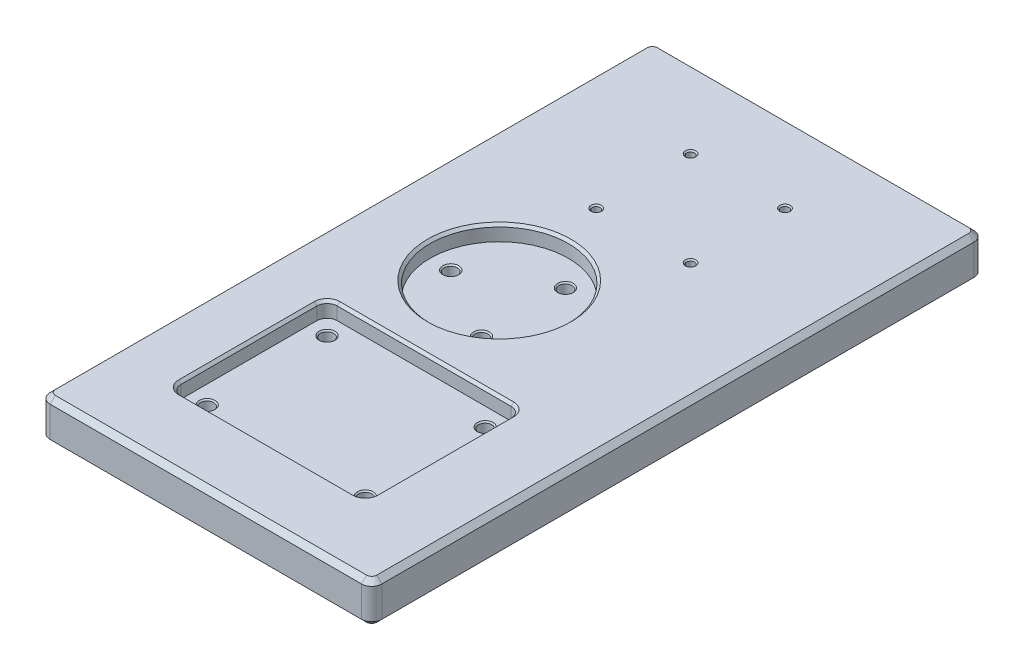
from build123d import *

# Parameters (mm, degrees)
SKETCH1_W           = 130
SKETCH1_H           = 240
BOSS_EXTRUDE1_DEPTH = 16
SKETCH7_W           = 76.2
SKETCH7_H           = 61.2
CUT_EXTRUDE5_DEPTH  = 6
SKETCH2_R           = 2.6
CUT_EXTRUDE1_DEPTH  = 11
SKETCH8_R           = 27.1
CUT_EXTRUDE6_DEPTH  = 6
SKETCH9_R           = 2.6
CUT_EXTRUDE7_DEPTH  = 11
SKETCH5_R           = 1.55
CUT_EXTRUDE3_DEPTH  = 17
SKETCH4_R           = 10
CUT_EXTRUDE2_DEPTH  = 5
SKETCH11_R          = 10
CUT_EXTRUDE8_DEPTH  = 6
FILLET1_R           = 4
CHAMFER3_SIZE       = 2
CHAMFER1_SIZE       = 1
CHAMFER2_SIZE       = 0.5


with BuildPart() as part:
    # Sketch1 → Boss-Extrude1 (new body)
    with BuildSketch(Plane(origin=(0, 0, 0), x_dir=(1, 0, 0), z_dir=(0, 1, 0))):
        Rectangle(SKETCH1_W, SKETCH1_H)
    extrude(amount=BOSS_EXTRUDE1_DEPTH)

    # Sketch7 → Cut-Extrude5 (cut)
    with BuildSketch(Plane(origin=(0, 16, 0), x_dir=(1, 0, 0), z_dir=(0, 1, 0))):
        with Locations((-3, -62)):
            Rectangle(SKETCH7_W, SKETCH7_H)
    extrude(amount=-CUT_EXTRUDE5_DEPTH, mode=Mode.SUBTRACT)

    # Sketch2 → Cut-Extrude1 (cut, through all)
    with BuildSketch(Plane(origin=(0, 10, 0), x_dir=(1, 0, 0), z_dir=(0, 1, 0))):
        with Locations((-34, -85.5)):
            Circle(SKETCH2_R)
        with Locations((-34, -38.5)):
            Circle(SKETCH2_R)
        with Locations((28, -38.5)):
            Circle(SKETCH2_R)
        with Locations((28, -85.5)):
            Circle(SKETCH2_R)
    extrude(amount=-CUT_EXTRUDE1_DEPTH, mode=Mode.SUBTRACT)

    # Sketch8 → Cut-Extrude6 (cut)
    with BuildSketch(Plane(origin=(0, 16, 0), x_dir=(1, 0, 0), z_dir=(0, 1, 0))):
        with Locations((-13, 8)):
            Circle(SKETCH8_R)
    extrude(amount=-CUT_EXTRUDE6_DEPTH, mode=Mode.SUBTRACT)

    # Sketch9 → Cut-Extrude7 (cut, through all)
    with BuildSketch(Plane(origin=(0, 10, 0), x_dir=(1, 0, 0), z_dir=(0, 1, 0))):
        with Locations((-32, 8)):
            Circle(SKETCH9_R)
        with Locations((-3.5, 24.454482672)):
            Circle(SKETCH9_R)
        with Locations((-3.5, -8.454482672)):
            Circle(SKETCH9_R)
    extrude(amount=-CUT_EXTRUDE7_DEPTH, mode=Mode.SUBTRACT)

    # Sketch5 → Cut-Extrude3 (cut, through all)
    with BuildSketch(Plane(origin=(0, 16, 0), x_dir=(1, 0, 0), z_dir=(0, 1, 0))):
        with Locations((-18.5, 51.5)):
            Circle(SKETCH5_R)
        with Locations((-18.5, 88.5)):
            Circle(SKETCH5_R)
        with Locations((18.5, 88.5)):
            Circle(SKETCH5_R)
        with Locations((18.5, 51.5)):
            Circle(SKETCH5_R)
    extrude(amount=-CUT_EXTRUDE3_DEPTH, mode=Mode.SUBTRACT)

    # Sketch4 → Cut-Extrude2 (cut)
    with BuildSketch(Plane.XZ):
        with Locations((-34, 85.5)):
            Circle(SKETCH4_R)
        with Locations((28, 85.5)):
            Circle(SKETCH4_R)
        with Locations((28, 38.5)):
            Circle(SKETCH4_R)
        with Locations((-34, 38.5)):
            Circle(SKETCH4_R)
        with Locations((-32, -8)):
            Circle(SKETCH4_R)
        with Locations((-3.5, 8.454482672)):
            Circle(SKETCH4_R)
        with Locations((-3.5, -24.454482672)):
            Circle(SKETCH4_R)
        with Locations((-18.5, -51.5)):
            Circle(SKETCH4_R)
        with Locations((-18.5, -88.5)):
            Circle(SKETCH4_R)
        with Locations((18.5, -88.5)):
            Circle(SKETCH4_R)
        with Locations((18.5, -51.5)):
            Circle(SKETCH4_R)
    extrude(amount=-CUT_EXTRUDE2_DEPTH, mode=Mode.SUBTRACT)

    # Sketch11 → Cut-Extrude8 (cut)
    with BuildSketch(Plane.XZ.offset(-5)):
        with Locations((18.5, -88.5)):
            Circle(SKETCH11_R)
        with Locations((-18.5, -88.5)):
            Circle(SKETCH11_R)
        with Locations((-18.5, -51.5)):
            Circle(SKETCH11_R)
        with Locations((18.5, -51.5)):
            Circle(SKETCH11_R)
    extrude(amount=-CUT_EXTRUDE8_DEPTH, mode=Mode.SUBTRACT)

    # Fillet1
    fillet1_edges = [part.edges().sort_by_distance(p)[0] for p in [
        (35.1, 13, 31.4),
        (35.1, 13, 92.6),
        (-41.1, 13, 92.6),
        (-41.1, 13, 31.4),
        (-65, 8, -120),
        (65, 8, -120),
        (65, 8, 120),
        (-65, 8, 120),
    ]]
    fillet(fillet1_edges, radius=FILLET1_R)

    # Chamfer3
    chamfer3_edges = [part.edges().sort_by_distance(p)[0] for p in [
        (-65, 0, 0),
        (-65, 16, 0),
        (0, 0, -120),
        (65, 0, 0),
        (0, 0, 120),
        (63.828427125, 0, 118.828427125),
        (-63.828427125, 0, 118.828427125),
        (63.828427125, 0, -118.828427125),
        (-63.828427125, 0, -118.828427125),
        (0, 16, -120),
        (0, 16, 120),
        (65, 16, 0),
        (63.828427125, 16, 118.828427125),
        (-63.828427125, 16, 118.828427125),
        (63.828427125, 16, -118.828427125),
        (-63.828427125, 16, -118.828427125),
    ]]
    chamfer(chamfer3_edges, length=CHAMFER3_SIZE)

    # Chamfer1
    chamfer1_edges = [part.edges().sort_by_distance(p)[0] for p in [
        (-13.5, 0, -24.454482672),
        (-13.5, 0, 8.454482672),
        (-42, 0, -8),
        (-44, 0, 38.5),
        (18, 0, 38.5),
        (18, 0, 85.5),
        (8.5, 0, -88.5),
        (8.5, 0, -51.5),
        (-44, 0, 85.5),
        (35.1, 16, 62),
        (-3, 16, 92.6),
        (-41.1, 16, 62),
        (-3, 16, 31.4),
        (33.928427125, 16, 32.571572875),
        (33.928427125, 16, 91.428427125),
        (-39.928427125, 16, 91.428427125),
        (-39.928427125, 16, 32.571572875),
        (-40.1, 16, -8),
        (-28.5, 0, -88.5),
        (-28.5, 0, -51.5),
    ]]
    chamfer(chamfer1_edges, length=CHAMFER1_SIZE)

    # Chamfer2
    chamfer2_edges = [part.edges().sort_by_distance(p)[0] for p in [
        (-6.1, 5, -24.454482672),
        (-6.1, 5, 8.454482672),
        (-34.6, 5, -8),
        (-36.6, 5, 38.5),
        (25.4, 5, 38.5),
        (25.4, 5, 85.5),
        (-36.6, 5, 85.5),
        (16.95, 11, -51.5),
        (-20.05, 11, -51.5),
        (-20.05, 11, -88.5),
        (16.95, 11, -88.5),
        (25.4, 10, 85.5),
        (25.4, 10, 38.5),
        (-36.6, 10, 38.5),
        (-36.6, 10, 85.5),
        (-34.6, 10, -8),
        (-6.1, 10, -24.454482672),
        (-6.1, 10, 8.454482672),
        (16.95, 16, -51.5),
        (16.95, 16, -88.5),
        (-20.05, 16, -88.5),
        (-20.05, 16, -51.5),
    ]]
    chamfer(chamfer2_edges, length=CHAMFER2_SIZE)


solid = part.part
